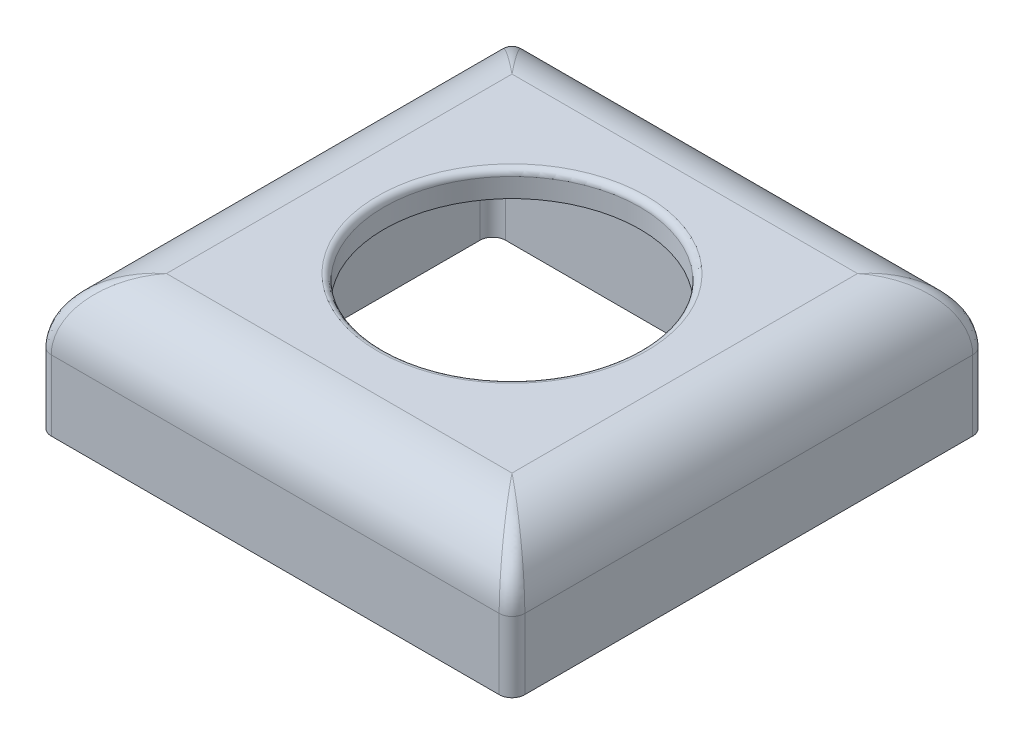
from build123d import *

# Parameters (mm, degrees)
SKETCH_1_W          = 37
SKETCH_1_H          = 37
EXTRUDE_1_DEPTH     = 10.5
SKETCH_2_R          = 10
CUT_EXTRUDE_1_DEPTH = 11.5
FILLET_1_R          = 5
FILLET_2_R          = 1
SKETCH_3_R          = 1.5
CUT_EXTRUDE_2_DEPTH = 4
CUT_EXTRUDE_3_DEPTH = 8.5
CUT_EXTRUDE_4_DEPTH = 8.5
FILLET_4_R          = 0.5


with BuildPart() as part:
    # 草图1 → 凸台-拉伸1 (new body)
    with BuildSketch(Plane(origin=(0, 0, 0), x_dir=(1, 0, 0), z_dir=(0, 1, 0))):
        Rectangle(SKETCH_1_W, SKETCH_1_H)
    extrude(amount=EXTRUDE_1_DEPTH)

    # 草图2 → 切除-拉伸1 (cut, through all)
    with BuildSketch(Plane.XZ):
        Circle(SKETCH_2_R)
    extrude(amount=-CUT_EXTRUDE_1_DEPTH, mode=Mode.SUBTRACT)

    # 圆角1
    fillet_1_edges = [part.edges().sort_by_distance(p)[0] for p in [
        (-18.5, 10.5, 0),
        (0, 10.5, 18.5),
        (18.5, 10.5, 0),
        (0, 10.5, -18.5),
    ]]
    fillet(fillet_1_edges, radius=FILLET_1_R)

    # 圆角2
    fillet_2_edges = [part.edges().sort_by_distance(p)[0] for p in [
        (18.5, 2.75, -18.5),
        (18.5, 2.75, 18.5),
        (-18.5, 2.75, 18.5),
        (-18.5, 2.75, -18.5),
        (-16.730244537, 9.316480084, 16.730244537),
        (-16.730244537, 9.316480084, -16.730244537),
        (16.730244537, 9.316480084, 16.730244537),
        (16.730244537, 9.316480084, -16.730244537),
    ]]
    fillet(fillet_2_edges, radius=FILLET_2_R)

    # 草图3 → 切除-拉伸2 (cut)
    with BuildSketch(Plane.XZ):
        with Locations((15, 15)):
            Circle(SKETCH_3_R)
        with Locations((15, -15)):
            Circle(SKETCH_3_R)
        with Locations((0, -15)):
            Circle(SKETCH_3_R)
        with Locations((-15, -15)):
            Circle(SKETCH_3_R)
        with Locations((-15, 15)):
            Circle(SKETCH_3_R)
        with Locations((0, 15)):
            Circle(SKETCH_3_R)
    extrude(amount=-CUT_EXTRUDE_2_DEPTH, mode=Mode.SUBTRACT)

    # 草图4 → 切除-拉伸3 (cut)
    with BuildSketch(Plane.XZ):
        with BuildLine():
            Line((13, 12.5), (-13, 12.5))
            ThreePointArc((-13, 12.5), (-13.707106781, 12.207106781), (-14, 11.5))
            Line((-14, 11.5), (-14, -11.5))
            ThreePointArc((-14, -11.5), (-13.707106781, -12.207106781), (-13, -12.5))
            Line((-13, -12.5), (13, -12.5))
            ThreePointArc((13, -12.5), (13.707106781, -12.207106781), (14, -11.5))
            Line((14, -11.5), (14, 11.5))
            ThreePointArc((14, 11.5), (13.707106781, 12.207106781), (13, 12.5))
        make_face()
    extrude(amount=-CUT_EXTRUDE_3_DEPTH, mode=Mode.SUBTRACT)

    # 草图5 → 切除-拉伸4 (cut)
    with BuildSketch(Plane.XZ):
        with BuildLine():
            Line((-17, 12.127718677), (-17, -12.127718677))
            ThreePointArc((-17, -12.127718677), (-16.284547708, -11.744245527), (-15.5, -11.535898385))
            Line((-15.5, -11.535898385), (-15.5, 11.535898385))
            ThreePointArc((-15.5, 11.535898385), (-16.284547708, 11.744245527), (-17, 12.127718677))
        make_face()
        with BuildLine():
            Line((-12.127718677, -17), (-2.872281323, -17))
            ThreePointArc((-2.872281323, -17), (-3.455714429, -15.555011516), (-3.354101966, -14))
            Line((-3.354101966, -14), (-11.645898034, -14))
            ThreePointArc((-11.645898034, -14), (-11.544285571, -15.555011516), (-12.127718677, -17))
        make_face()
        with BuildLine():
            Line((17, -12.127718677), (17, 12.127718677))
            ThreePointArc((17, 12.127718677), (16.284547708, 11.744245527), (15.5, 11.535898385))
            Line((15.5, 11.535898385), (15.5, -11.535898385))
            ThreePointArc((15.5, -11.535898385), (16.284547708, -11.744245527), (17, -12.127718677))
        make_face()
        with BuildLine():
            Line((12.127718677, 17), (2.872281323, 17))
            ThreePointArc((2.872281323, 17), (3.455714429, 15.555011516), (3.354101966, 14))
            Line((3.354101966, 14), (11.645898034, 14))
            ThreePointArc((11.645898034, 14), (11.544285571, 15.555011516), (12.127718677, 17))
        make_face()
        with BuildLine():
            Line((-3.354101966, 14), (-11.645898034, 14))
            ThreePointArc((-11.645898034, 14), (-11.544285571, 15.555011516), (-12.127718677, 17))
            Line((-12.127718677, 17), (-2.872281323, 17))
            ThreePointArc((-2.872281323, 17), (-3.455714429, 15.555011516), (-3.354101966, 14))
        make_face()
        with BuildLine():
            Line((2.872281323, -17), (12.127718677, -17))
            ThreePointArc((12.127718677, -17), (11.544285571, -15.555011516), (11.645898034, -14))
            Line((11.645898034, -14), (3.354101966, -14))
            ThreePointArc((3.354101966, -14), (3.455714429, -15.555011516), (2.872281323, -17))
        make_face()
    extrude(amount=-CUT_EXTRUDE_4_DEPTH, mode=Mode.SUBTRACT)

    # 圆角4
    fillet_4_edges = [part.edges().sort_by_distance(p)[0] for p in [
        (-10, 10.5, 0),
    ]]
    fillet(fillet_4_edges, radius=FILLET_4_R)


solid = part.part
